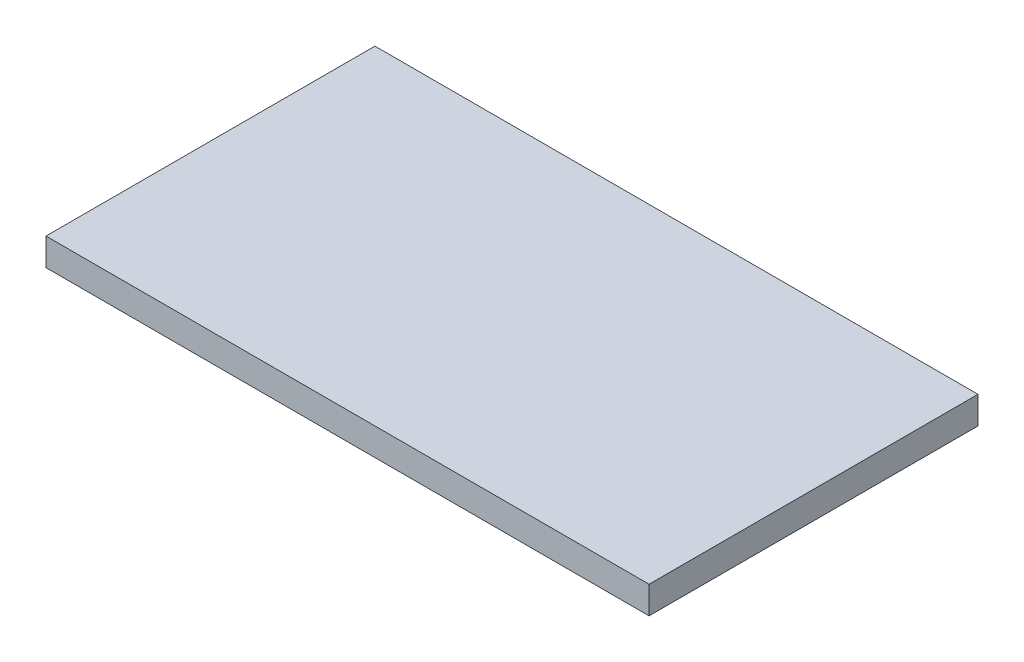
from build123d import *

# Parameters (mm, degrees)
SKETCH1_W           = 22
SKETCH1_H           = 12
BOSS_EXTRUDE1_DEPTH = 1


with BuildPart() as part:
    # Sketch1 → Boss-Extrude1 (new body)
    with BuildSketch(Plane(origin=(0, 0, 0), x_dir=(1, 0, 0), z_dir=(0, 1, 0))):
        with Locations((-11, 6)):
            Rectangle(SKETCH1_W, SKETCH1_H)
    extrude(amount=BOSS_EXTRUDE1_DEPTH)


solid = part.part
